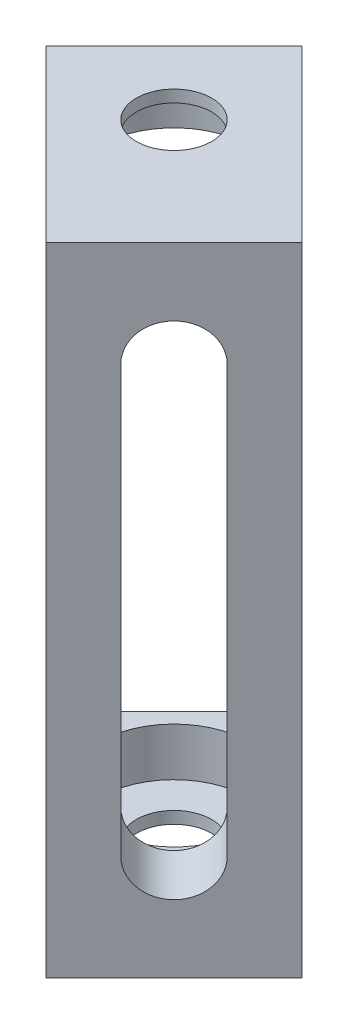
from build123d import *

# Parameters (mm, degrees)
SKETCH1_W                                           = 7.62
SKETCH1_H                                           = 26.854156748
BOSS_EXTRUDE1_DEPTH                                 = 2.54
SKETCH2_W                                           = 7.62
SKETCH2_H                                           = 2.54
BOSS_EXTRUDE2_DEPTH                                 = 7.62
CBORE_FOR_4_BINDING_HEAD_MACHINE_SCREW3_D           = 3.175
CBORE_FOR_4_BINDING_HEAD_MACHINE_SCREW3_DEPTH       = 2.54
CBORE_FOR_4_BINDING_HEAD_MACHINE_SCREW3_CBORE_D     = 6.35
CBORE_FOR_4_BINDING_HEAD_MACHINE_SCREW3_CBORE_DEPTH = 2.032
CBORE_FOR_4_BINDING_HEAD_MACHINE_SCREW4_D           = 3.175
CBORE_FOR_4_BINDING_HEAD_MACHINE_SCREW4_DEPTH       = 2.54
CBORE_FOR_4_BINDING_HEAD_MACHINE_SCREW4_CBORE_D     = 6.35
CBORE_FOR_4_BINDING_HEAD_MACHINE_SCREW4_CBORE_DEPTH = 2.032


with BuildPart() as part:
    # Sketch1 → Boss-Extrude1 (new body)
    with BuildSketch(Plane(origin=(-67.768700971, 0, -67.768700971), x_dir=(0.707106781, 0, -0.707106781), z_dir=(0.707106781, 0, 0.707106781))):
        with Locations((-15.829754227, 13.427078374)):
            Rectangle(SKETCH1_W, SKETCH1_H)
        with BuildLine():
            Line((-14.242254227, 22.409156748), (-14.242254227, 4.445))
            ThreePointArc((-14.242254227, 4.445), (-15.829754227, 2.8575), (-17.417254227, 4.445))
            Line((-17.417254227, 4.445), (-17.417254227, 22.409156748))
            ThreePointArc((-17.417254227, 22.409156748), (-15.829754227, 23.996656748), (-14.242254227, 22.409156748))
        make_face(mode=Mode.SUBTRACT)
    extrude(amount=-BOSS_EXTRUDE1_DEPTH)

    # Sketch2 → Boss-Extrude2 (add)
    with BuildSketch(Plane(origin=(-69.564752195, 0, -69.564752195), x_dir=(-0.707106781, 0, 0.707106781), z_dir=(-0.707106781, 0, -0.707106781))):
        with Locations((15.829754227, 25.584156748)):
            Rectangle(SKETCH2_W, SKETCH2_H)
        with Locations((15.829754227, 1.27)):
            Rectangle(SKETCH2_W, SKETCH2_H)
    extrude(amount=BOSS_EXTRUDE2_DEPTH)

    # CBORE for #4 Binding Head Machine Screw3
    with Locations(Plane(origin=(0, 2.54, 0), x_dir=(1, 0, 0), z_dir=(0, 1, 0))):
        with Locations((-83.45215559, 61.065502473)):
            CounterBoreHole(CBORE_FOR_4_BINDING_HEAD_MACHINE_SCREW3_D / 2, CBORE_FOR_4_BINDING_HEAD_MACHINE_SCREW3_CBORE_D / 2, CBORE_FOR_4_BINDING_HEAD_MACHINE_SCREW3_CBORE_DEPTH, depth=CBORE_FOR_4_BINDING_HEAD_MACHINE_SCREW3_DEPTH)

    # CBORE for #4 Binding Head Machine Screw4
    with Locations(Plane(origin=(0, 24.314156748, 0), x_dir=(-1, 0, 0), z_dir=(0, -1, 0))):
        with Locations((83.45215559, 61.065502473)):
            CounterBoreHole(CBORE_FOR_4_BINDING_HEAD_MACHINE_SCREW4_D / 2, CBORE_FOR_4_BINDING_HEAD_MACHINE_SCREW4_CBORE_D / 2, CBORE_FOR_4_BINDING_HEAD_MACHINE_SCREW4_CBORE_DEPTH, depth=CBORE_FOR_4_BINDING_HEAD_MACHINE_SCREW4_DEPTH)


solid = part.part
